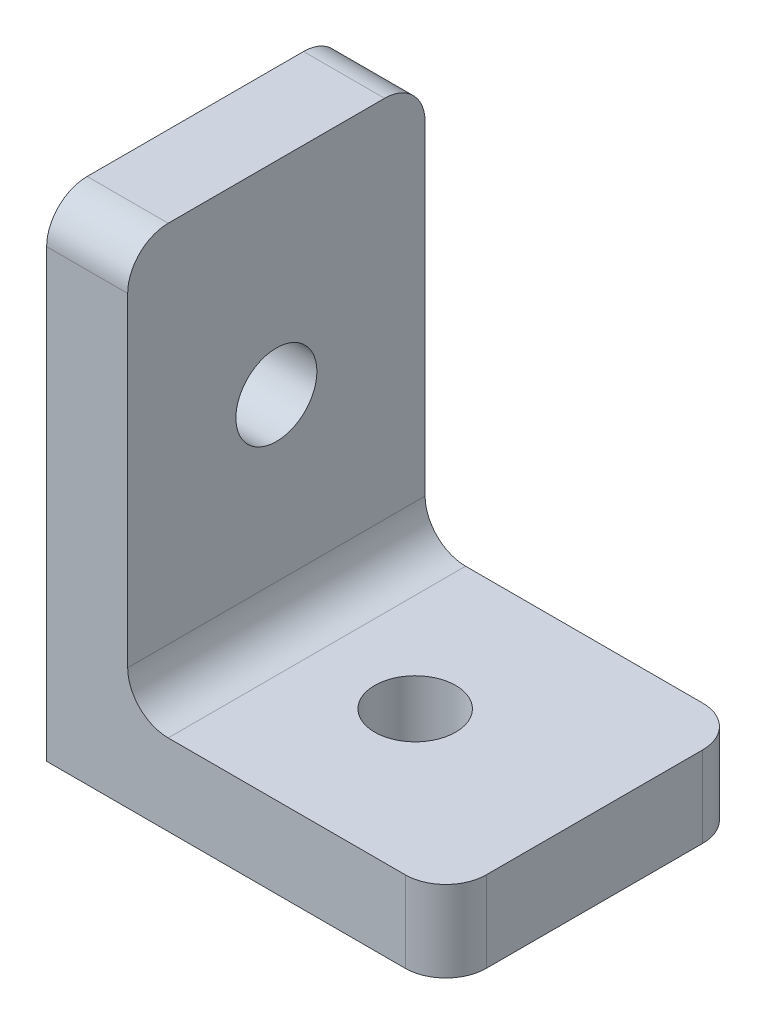
from build123d import *

# Parameters (mm, degrees)
SKETCH3_W           = 19.70074215
SKETCH3_H           = 14.68
SKETCH3_R           = 2
BOSS_EXTRUDE2_DEPTH = 4
SKETCH5_W           = 4
SKETCH5_H           = 14.68
BOSS_EXTRUDE3_DEPTH = 20
SKETCH6_R           = 2
CUT_EXTRUDE1_DEPTH  = 10
FILLET1_R           = 2


with BuildPart() as part:
    # Sketch3 → Boss-Extrude2 (new body)
    with BuildSketch(Plane(origin=(0, 0, 0), x_dir=(1, 0, 0), z_dir=(0, 1, 0))):
        with Locations((0.919743343, 1.910780827)):
            Rectangle(SKETCH3_W, SKETCH3_H)
        with Locations((1.919743345, 1.910780827)):
            Circle(SKETCH3_R, mode=Mode.SUBTRACT)
    extrude(amount=BOSS_EXTRUDE2_DEPTH)

    # Sketch5 → Boss-Extrude3 (add)
    with BuildSketch(Plane(origin=(0, 4, 0), x_dir=(1, 0, 0), z_dir=(0, 1, 0))):
        with Locations((-6.930627732, 1.910780827)):
            Rectangle(SKETCH5_W, SKETCH5_H)
    extrude(amount=BOSS_EXTRUDE3_DEPTH)

    # Sketch6 → Cut-Extrude1 (cut)
    with BuildSketch(Plane(origin=(-4.930627732, 0, 0), x_dir=(0, 0, -1), z_dir=(1, 0, 0))):
        with Locations((1.910780827, 14)):
            Circle(SKETCH6_R)
    extrude(amount=-CUT_EXTRUDE1_DEPTH, mode=Mode.SUBTRACT)

    # Fillet1
    fillet1_edges = [part.edges().sort_by_distance(p)[0] for p in [
        (-4.930627732, 4, -1.910780827),
        (-6.930627732, 24, 5.429219173),
        (-6.930627732, 24, -9.250780827),
        (10.770114418, 2, -9.250780827),
        (10.770114418, 2, 5.429219173),
    ]]
    fillet(fillet1_edges, radius=FILLET1_R)


solid = part.part
